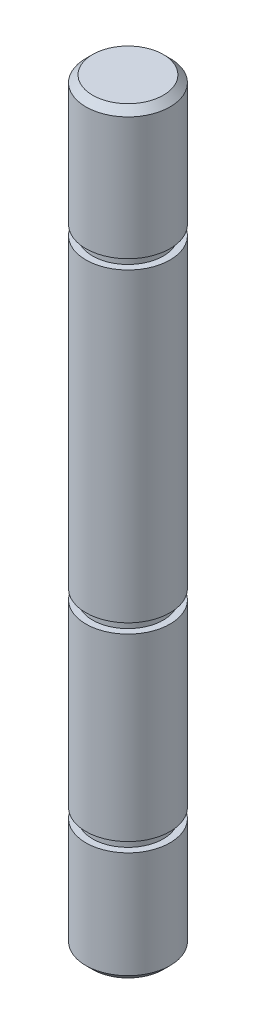
from build123d import *

# Parameters (mm, degrees)
CHAMFER1_SIZE = 0.508


with BuildPart() as part:
    # Sketch1 → Revolve1 (revolve)
    with BuildSketch(Plane.XY):
        Polygon((-3.175, 47.3738), (-3.175, 57.15), (0, 57.15), (0, 0), (-3.175, 0), (-3.175, 8.5372), (-2.667, 8.5372), (-2.667, 9.2738), (-3.175, 9.2738), (-3.175, 22.8374), (-2.667, 22.8374), (-2.667, 23.574), (-3.175, 23.574), (-3.175, 46.6372), (-2.667, 46.6372), (-2.667, 47.3738), align=None)
    revolve(axis=Axis((0, 0, 0), (0, -1, 0)))

    # Chamfer1
    chamfer1_edges = [part.edges().sort_by_distance(p)[0] for p in [
        (3.175, 0, 0),
        (3.175, 57.15, 0),
    ]]
    chamfer(chamfer1_edges, length=CHAMFER1_SIZE)


solid = part.part
